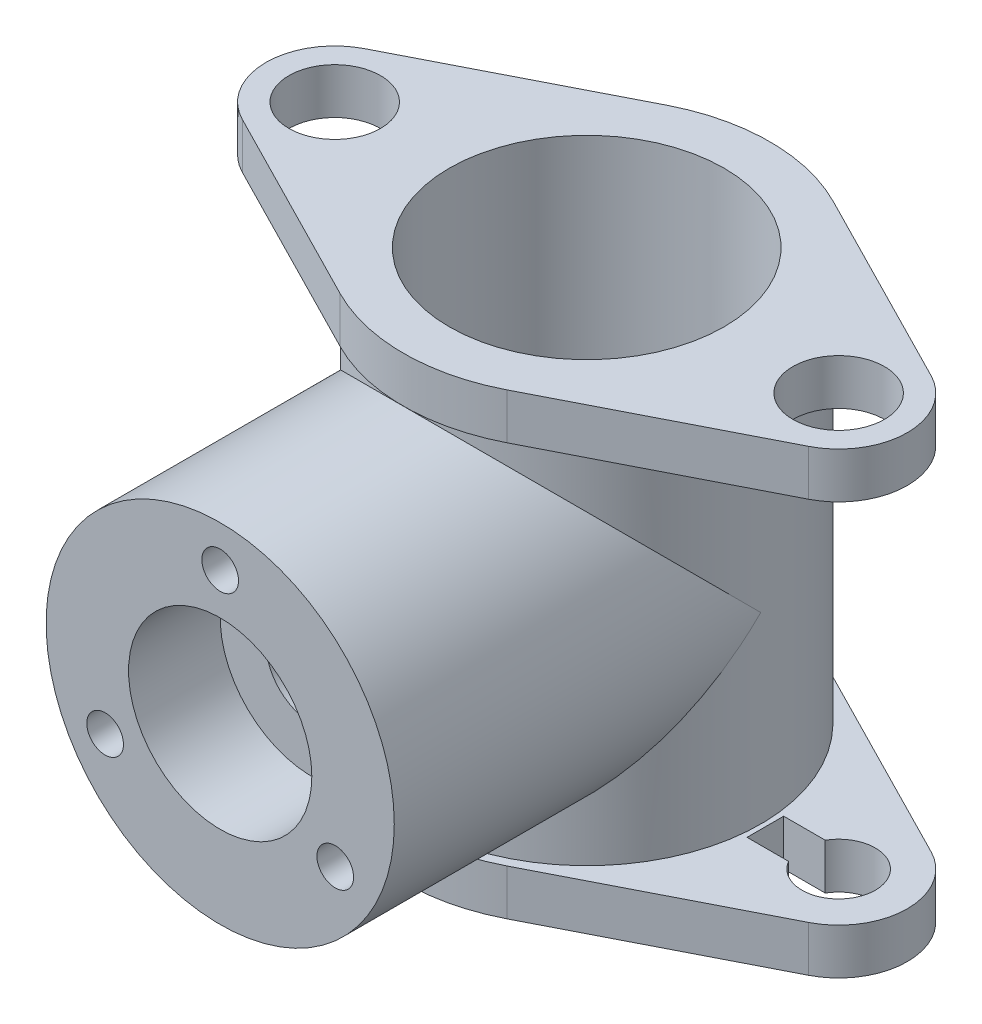
from build123d import *

# Parameters (mm, degrees)
SKETCH1_R           = 15
BOSS_EXTRUDE1_DEPTH = 5
SKETCH2_R           = 19
SKETCH2_R_2         = 15
BOSS_EXTRUDE2_DEPTH = 40
SKETCH3_R           = 5
SKETCH3_R_2         = 15
BOSS_EXTRUDE4_DEPTH = 5
BOSS_EXTRUDE5_REACH = 62
SKETCH4_R           = 19
SKETCH5_R           = 10
CUT_EXTRUDE1_DEPTH  = 10
SKETCH6_R           = 5
CUT_EXTRUDE2_DEPTH  = 48
BOSS_EXTRUDE6_REACH = 62
SKETCH7_R           = 6
SKETCH8_R           = 2
CUT_EXTRUDE3_DEPTH  = 15


with BuildPart() as part:
    # Sketch1 → Boss-Extrude1 (new body)
    with BuildSketch(Plane(origin=(0, 0, 0), x_dir=(1, 0, 0), z_dir=(0, 1, 0))):
        with BuildLine():
            Line((-9.090909091, 17.814470857), (-30.909090909, 6.680426571))
            ThreePointArc((-30.909090909, 6.680426571), (-35, 0), (-30.909090909, -6.680426571))
            Line((-30.909090909, -6.680426571), (-9.090909091, -17.814470857))
            ThreePointArc((-9.090909091, -17.814470857), (0, -20), (9.090909091, -17.814470857))
            Line((9.090909091, -17.814470857), (30.909090909, -6.680426571))
            ThreePointArc((30.909090909, -6.680426571), (35, 0), (30.909090909, 6.680426571))
            Line((30.909090909, 6.680426571), (9.090909091, 17.814470857))
            ThreePointArc((9.090909091, 17.814470857), (0, 20), (-9.090909091, 17.814470857))
        make_face()
        Circle(SKETCH1_R, mode=Mode.SUBTRACT)
        with BuildLine():
            Line((-23.5, 2), (-24.035898385, 2))
            ThreePointArc((-24.035898385, 2), (-31.5, 0), (-24.035898385, -2))
            Line((-24.035898385, -2), (-23.5, -2))
            Line((-23.5, -2), (-19.5, -2))
            Line((-19.5, -2), (-19.5, 2))
            Line((-19.5, 2), (-23.5, 2))
        make_face(mode=Mode.SUBTRACT)
        with BuildLine():
            Line((23.5, 2), (24.035898385, 2))
            ThreePointArc((24.035898385, 2), (31.5, 0), (24.035898385, -2))
            Line((24.035898385, -2), (23.5, -2))
            Line((23.5, -2), (19.5, -2))
            Line((19.5, -2), (19.5, 2))
            Line((19.5, 2), (23.5, 2))
        make_face(mode=Mode.SUBTRACT)
    extrude(amount=BOSS_EXTRUDE1_DEPTH)

    # Sketch2 → Boss-Extrude2 (add)
    with BuildSketch(Plane(origin=(0, 5, 0), x_dir=(1, 0, 0), z_dir=(0, 1, 0))):
        Circle(SKETCH2_R)
        Circle(SKETCH2_R_2, mode=Mode.SUBTRACT)
    extrude(amount=BOSS_EXTRUDE2_DEPTH)

    # Sketch3 → Boss-Extrude4 (add)
    with BuildSketch(Plane(origin=(0, 45, 0), x_dir=(1, 0, 0), z_dir=(0, 1, 0))):
        with BuildLine():
            Line((9.090909091, -17.814470857), (30.909090909, -6.680426571))
            ThreePointArc((30.909090909, -6.680426571), (35, 0), (30.909090909, 6.680426571))
            Line((30.909090909, 6.680426571), (9.090909091, 17.814470857))
            ThreePointArc((9.090909091, 17.814470857), (0, 20), (-9.090909091, 17.814470857))
            Line((-9.090909091, 17.814470857), (-30.909090909, 6.680426571))
            ThreePointArc((-30.909090909, 6.680426571), (-35, 0), (-30.909090909, -6.680426571))
            Line((-30.909090909, -6.680426571), (-9.090909091, -17.814470857))
            ThreePointArc((-9.090909091, -17.814470857), (0, -20), (9.090909091, -17.814470857))
        make_face()
        with Locations((-27.5, 0)):
            Circle(SKETCH3_R, mode=Mode.SUBTRACT)
        with Locations((27.5, 0)):
            Circle(SKETCH3_R, mode=Mode.SUBTRACT)
        Circle(SKETCH3_R_2, mode=Mode.SUBTRACT)
    extrude(amount=BOSS_EXTRUDE4_DEPTH)

    # Sketch4 → Boss-Extrude5 (add, up to next)
    with BuildSketch(Plane.XY.offset(40), mode=Mode.PRIVATE) as boss_extrude5_sk1:
        with Locations((0, 25)):
            Circle(SKETCH4_R)
    boss_extrude5_tool1 = extrude(boss_extrude5_sk1.sketch, amount=-BOSS_EXTRUDE5_REACH, mode=Mode.PRIVATE) - part.part
    add(boss_extrude5_tool1.solids().sort_by_distance((0, 25, 40))[0])

    # Sketch5 → Cut-Extrude1 (cut)
    with BuildSketch(Plane.XY.offset(40)):
        with Locations((0, 25)):
            Circle(SKETCH5_R)
    extrude(amount=-CUT_EXTRUDE1_DEPTH, mode=Mode.SUBTRACT)

    # Sketch6 → Cut-Extrude2 (cut)
    with BuildSketch(Plane.XY.offset(30)):
        with Locations((0, 25)):
            Circle(SKETCH6_R)
    extrude(amount=-CUT_EXTRUDE2_DEPTH, mode=Mode.SUBTRACT)

    # Sketch7 → Boss-Extrude6 (add, up to next)
    with BuildSketch(Plane.XY.offset(-20), mode=Mode.PRIVATE) as boss_extrude6_sk1:
        with Locations((0, 25)):
            Circle(SKETCH7_R)
    boss_extrude6_tool1 = extrude(boss_extrude6_sk1.sketch, amount=BOSS_EXTRUDE6_REACH, mode=Mode.PRIVATE) - part.part
    add(boss_extrude6_tool1.solids().sort_by_distance((0, 25, -20))[0])

    # Sketch8 → Cut-Extrude3 (cut)
    with BuildSketch(Plane.XY.offset(40)):
        with Locations((0, 39.5)):
            Circle(SKETCH8_R)
        with Locations((12.557368355, 17.75)):
            Circle(SKETCH8_R)
        with Locations((-12.557368355, 17.75)):
            Circle(SKETCH8_R)
    extrude(amount=-CUT_EXTRUDE3_DEPTH, mode=Mode.SUBTRACT)


solid = part.part
